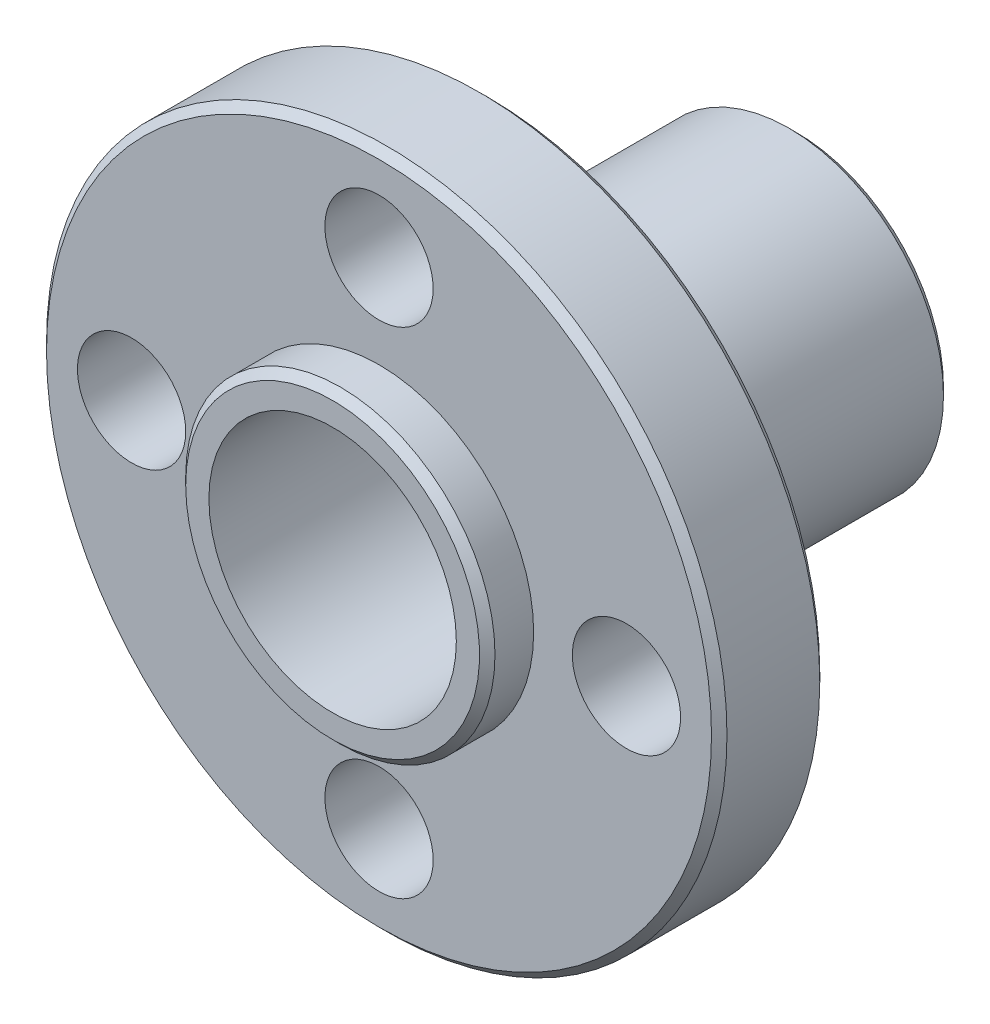
from build123d import *

# Parameters (mm, degrees)
CHAMFER1_SIZE      = 0.25
CUT_EXTRUDE1_REACH = 15.5
SKETCH2_R          = 1.75


with BuildPart() as part:
    # Sketch1 → Revolve1 (revolve)
    with BuildSketch(Plane(origin=(0, 0, 0), x_dir=(0, 0, -1), z_dir=(1, 0, 0))):
        Polygon((0, 4), (15, 4), (15, 5), (5, 5), (5, 11), (1.5, 11), (1.5, 5), (0, 5), align=None)
    revolve(axis=Axis((0, 0, 903.973270396), (0, 0, -1)))

    # Chamfer1
    chamfer1_edges = [part.edges().sort_by_distance(p)[0] for p in [
        (0, -5, 0),
        (0, -11, -1.5),
        (0, -11, -5),
        (0, -5, -15),
    ]]
    chamfer(chamfer1_edges, length=CHAMFER1_SIZE)

    # Sketch2 → Cut-Extrude1 (cut, up to next)
    with BuildSketch(Plane.XY.offset(-1.5), mode=Mode.PRIVATE) as cut_extrude1_sk1:
        with Locations((0, 8)):
            Circle(SKETCH2_R)
    cut_extrude1_tool1 = extrude(cut_extrude1_sk1.sketch, amount=-CUT_EXTRUDE1_REACH, mode=Mode.PRIVATE) & part.part
    add(cut_extrude1_tool1.solids().sort_by_distance((0, 8, -1.5))[0], mode=Mode.SUBTRACT)
    # Sketch2 → Cut-Extrude1 (cut, up to next)
    with BuildSketch(Plane.XY.offset(-1.5), mode=Mode.PRIVATE) as cut_extrude1_sk2:
        with Locations((8, 0)):
            Circle(SKETCH2_R)
    cut_extrude1_tool2 = extrude(cut_extrude1_sk2.sketch, amount=-CUT_EXTRUDE1_REACH, mode=Mode.PRIVATE) & part.part
    add(cut_extrude1_tool2.solids().sort_by_distance((8, 0, -1.5))[0], mode=Mode.SUBTRACT)
    # Sketch2 → Cut-Extrude1 (cut, up to next)
    with BuildSketch(Plane.XY.offset(-1.5), mode=Mode.PRIVATE) as cut_extrude1_sk3:
        with Locations((0, -8)):
            Circle(SKETCH2_R)
    cut_extrude1_tool3 = extrude(cut_extrude1_sk3.sketch, amount=-CUT_EXTRUDE1_REACH, mode=Mode.PRIVATE) & part.part
    add(cut_extrude1_tool3.solids().sort_by_distance((0, -8, -1.5))[0], mode=Mode.SUBTRACT)
    # Sketch2 → Cut-Extrude1 (cut, up to next)
    with BuildSketch(Plane.XY.offset(-1.5), mode=Mode.PRIVATE) as cut_extrude1_sk4:
        with Locations((-8, 0)):
            Circle(SKETCH2_R)
    cut_extrude1_tool4 = extrude(cut_extrude1_sk4.sketch, amount=-CUT_EXTRUDE1_REACH, mode=Mode.PRIVATE) & part.part
    add(cut_extrude1_tool4.solids().sort_by_distance((-8, 0, -1.5))[0], mode=Mode.SUBTRACT)


solid = part.part
